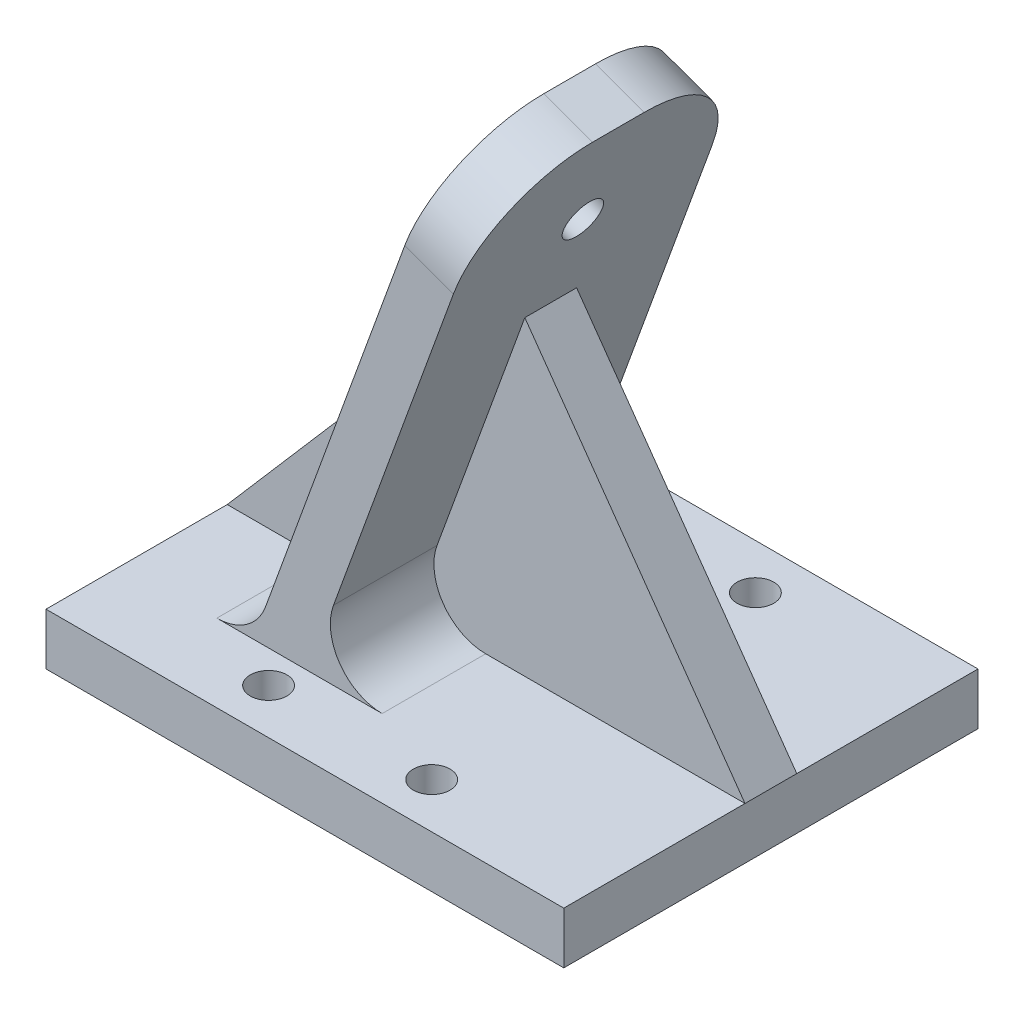
from build123d import *

# Parameters (mm, degrees)
SKETCH1_W           = 63.5
SKETCH1_H           = 50.8
BOSS_EXTRUDE1_DEPTH = 6.35
BOSS_EXTRUDE2_DEPTH = 15.875
FILLET1_R           = 12.7
FILLET2_R           = 6.35
BOSS_EXTRUDE5_DEPTH = 3.175
SKETCH5_R           = 2.413
CUT_EXTRUDE3_DEPTH  = 47.925927366
SKETCH8_R           = 2.25
CUT_EXTRUDE4_DEPTH  = 7.35


with BuildPart() as part:
    # Sketch1 → Boss-Extrude1 (new body)
    with BuildSketch(Plane(origin=(0, 0, 0), x_dir=(1, 0, 0), z_dir=(0, 1, 0))):
        Rectangle(SKETCH1_W, SKETCH1_H)
    extrude(amount=BOSS_EXTRUDE1_DEPTH)

    # Sketch2 → Boss-Extrude2 (add, symmetric)
    with BuildSketch(Plane.XY):
        Polygon((-11.43, 0), (13.036574415, 67.221360736), (7.069526273, 69.393188646), (-17.397048142, 2.17182791), align=None)
    extrude(amount=BOSS_EXTRUDE2_DEPTH, both=True)

    # Fillet1
    fillet1_edges = [part.edges().sort_by_distance(p)[0] for p in [
        (10.053050344, 68.307274691, 15.875),
        (10.053050344, 68.307274691, -15.875),
    ]]
    fillet(fillet1_edges, radius=FILLET1_R)

    # Fillet2
    fillet2_edges = [part.edges().sort_by_distance(p)[0] for p in [
        (-15.876317868, 6.35, 0),
        (-9.118789012, 6.35, 0),
    ]]
    fillet(fillet2_edges, radius=FILLET2_R)

    # Sketch7 → Boss-Extrude5 (add, symmetric)
    with BuildSketch(Plane.XY):
        with BuildLine():
            Line((4.748476913, 44.45), (31.75, 6.35))
            Line((31.75, 6.35), (-0.05004917, 6.35))
            ThreePointArc((-0.05004917, 6.35), (-5.251664651, 9.057789629), (-6.017097312, 14.87182791))
            Line((-6.017097312, 14.87182791), (4.748476913, 44.45))
        make_face()
        with BuildLine():
            Line((-31.75, 6.35), (-20.322635735, 6.35))
            ThreePointArc((-20.322635735, 6.35), (-16.680425364, 7.498384519), (-14.355587593, 10.52817209))
            Line((-14.355587593, 10.52817209), (-4.32026293, 38.1))
            Line((-4.32026293, 38.1), (-31.75, 6.35))
        make_face()
    extrude(amount=BOSS_EXTRUDE5_DEPTH, both=True)

    # Sketch5 → Cut-Extrude3 (cut, through all)
    with BuildSketch(Plane(origin=(-16.059992134, 5.845359099, 0), x_dir=(0, 0, 1), z_dir=(-0.939692621, 0.342020143, 0))):
        with Locations((0, 54.926187693)):
            Circle(SKETCH5_R)
    extrude(amount=-CUT_EXTRUDE3_DEPTH, mode=Mode.SUBTRACT)

    # Sketch8 → Cut-Extrude4 (cut, through all)
    with BuildSketch(Plane(origin=(0, 6.35, 0), x_dir=(1, 0, 0), z_dir=(0, 1, 0))):
        with Locations((10, -19.85)):
            Circle(SKETCH8_R)
        with Locations((10, 19.85)):
            Circle(SKETCH8_R)
        with Locations((-10, 19.85)):
            Circle(SKETCH8_R)
        with Locations((-10, -19.85)):
            Circle(SKETCH8_R)
    extrude(amount=-CUT_EXTRUDE4_DEPTH, mode=Mode.SUBTRACT)


solid = part.part
